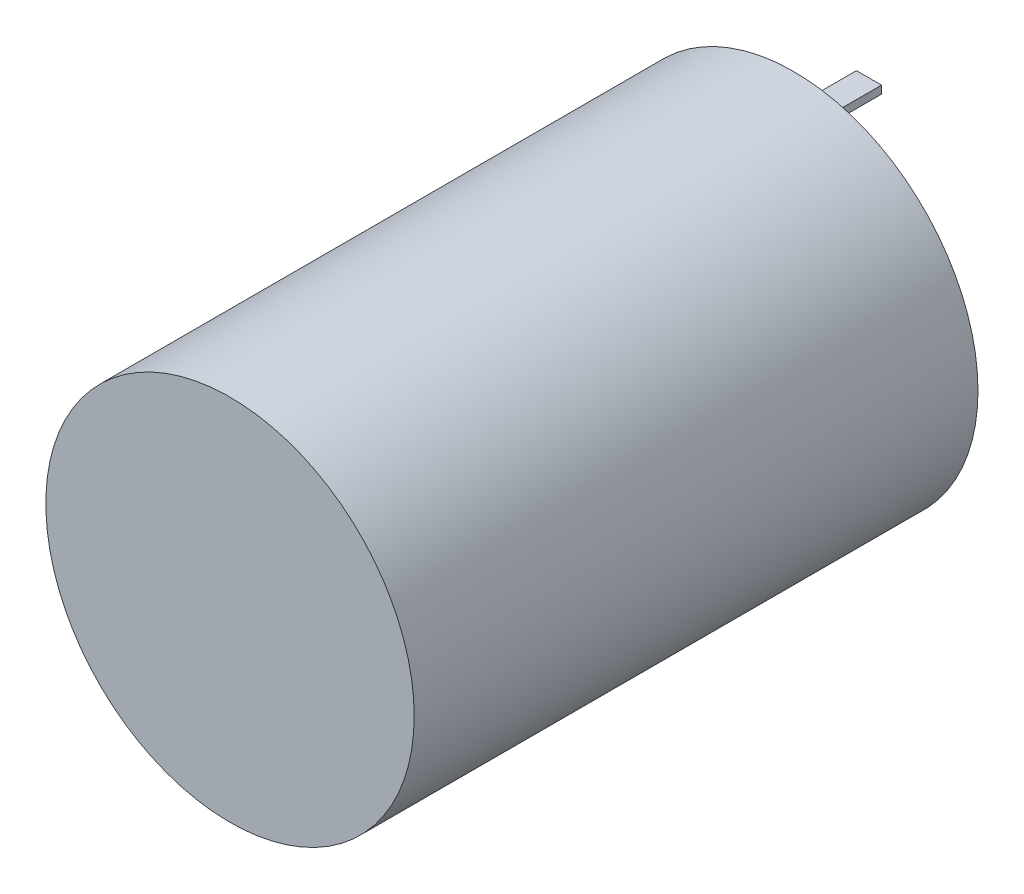
from build123d import *

# Parameters (mm, degrees)
SKETCH1_R           = 18.669
BOSS_EXTRUDE1_DEPTH = 57.15
SKETCH2_W           = 2.54
SKETCH2_H           = 0.79375
BOSS_EXTRUDE2_DEPTH = 7.62


with BuildPart() as part:
    # Sketch1 → Boss-Extrude1 (new body)
    with BuildSketch(Plane.XY):
        Circle(SKETCH1_R)
    extrude(amount=BOSS_EXTRUDE1_DEPTH)

    # Sketch2 → Boss-Extrude2 (add)
    with BuildSketch(Plane(origin=(0, 0, 0), x_dir=(-1, 0, 0), z_dir=(0, 0, -1))):
        with Locations((0, 13.9065)):
            Rectangle(SKETCH2_W, SKETCH2_H)
        with Locations((0, -13.9065)):
            Rectangle(SKETCH2_W, SKETCH2_H)
    extrude(amount=BOSS_EXTRUDE2_DEPTH)


solid = part.part
